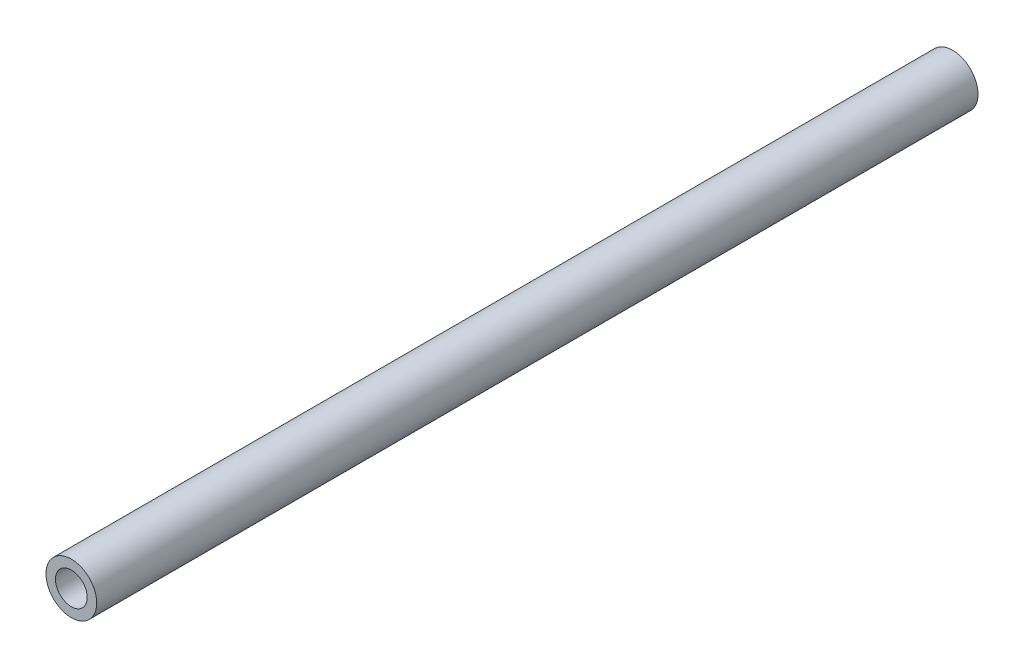
from build123d import *

# Parameters (mm, degrees)
SKETCH1_R           = 8.55
SKETCH1_R_2         = 5.35
BOSS_EXTRUDE1_DEPTH = 296.85


with BuildPart() as part:
    # Sketch1 → Boss-Extrude1 (new body)
    with BuildSketch(Plane.XY):
        Circle(SKETCH1_R)
        Circle(SKETCH1_R_2, mode=Mode.SUBTRACT)
    extrude(amount=-BOSS_EXTRUDE1_DEPTH)


solid = part.part
